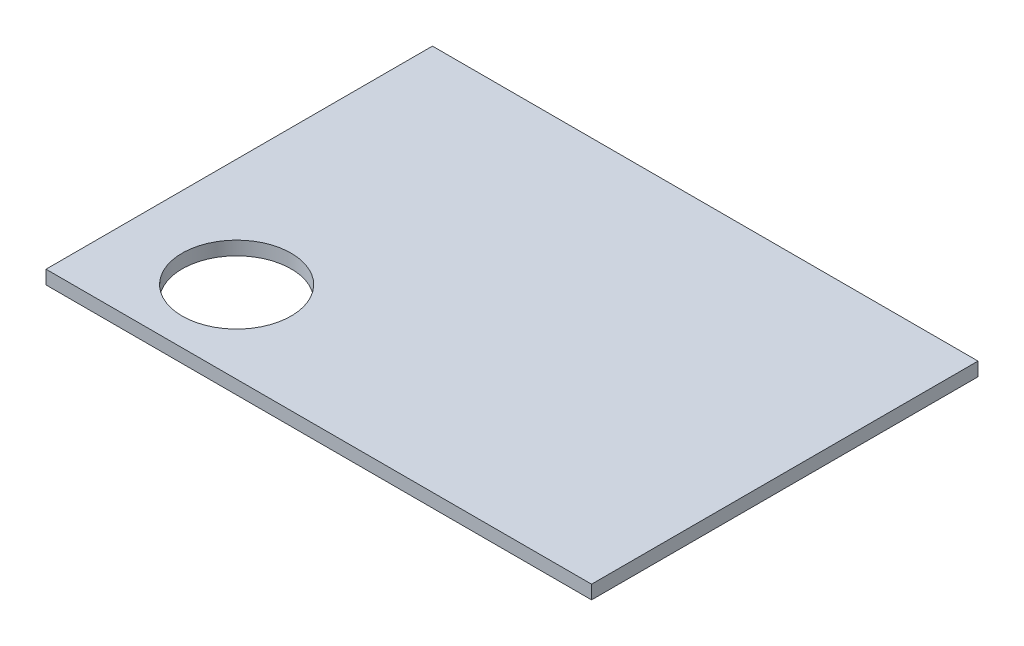
from build123d import *

# Parameters (mm, degrees)
SKETCH1_W           = 120
SKETCH1_H           = 85
BOSS_EXTRUDE1_DEPTH = 3
SKETCH2_R           = 11.99
CUT_EXTRUDE1_DEPTH  = 3


with BuildPart() as part:
    # Sketch1 → Boss-Extrude1 (new body)
    with BuildSketch(Plane(origin=(0, 0, 0), x_dir=(1, 0, 0), z_dir=(0, 1, 0))):
        Rectangle(SKETCH1_W, SKETCH1_H)
    extrude(amount=BOSS_EXTRUDE1_DEPTH)

    # Sketch2 → Cut-Extrude1 (cut)
    with BuildSketch(Plane(origin=(0, 3, 0), x_dir=(1, 0, 0), z_dir=(0, 1, 0))):
        with Locations((-36.1, -24.47)):
            Circle(SKETCH2_R)
    extrude(amount=-CUT_EXTRUDE1_DEPTH, mode=Mode.SUBTRACT)


solid = part.part
